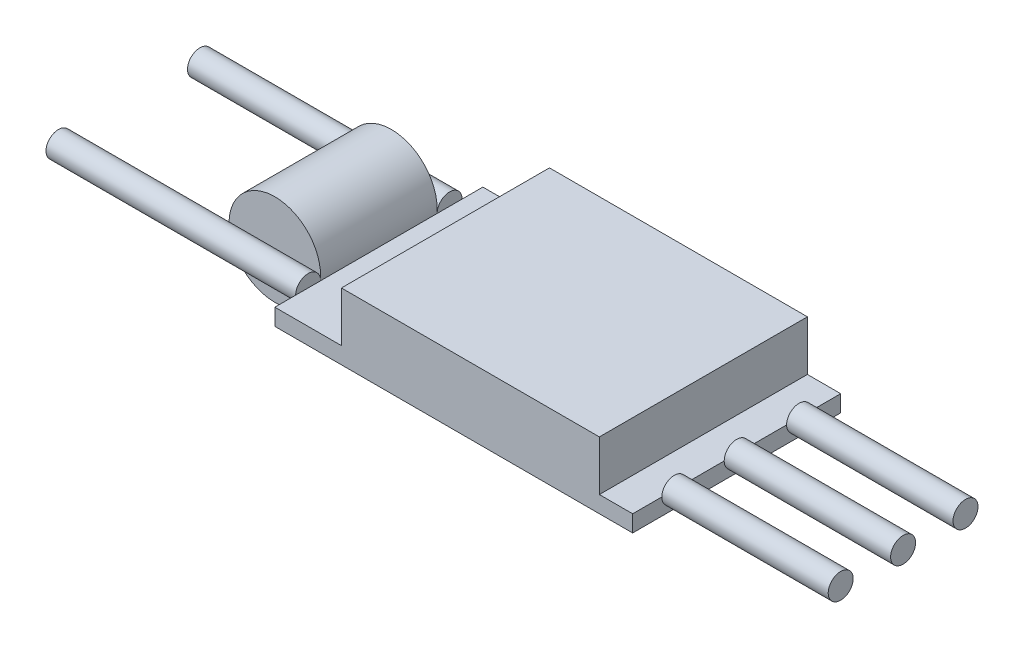
from build123d import *

# Parameters (mm, degrees)
SKETCH1_W           = 43
SKETCH1_H           = 25
BOSS_EXTRUDE1_DEPTH = 2
SKETCH2_R           = 5.5
BOSS_EXTRUDE2_DEPTH = 7
SKETCH3_W           = 31
SKETCH3_H           = 25
BOSS_EXTRUDE3_DEPTH = 6
SKETCH4_R           = 1.5
BOSS_EXTRUDE4_DEPTH = 30
SKETCH5_R           = 1.5
BOSS_EXTRUDE5_DEPTH = 20


with BuildPart() as part:
    # Sketch1 → Boss-Extrude1 (new body)
    with BuildSketch(Plane(origin=(0, 0, 0), x_dir=(1, 0, 0), z_dir=(0, 1, 0))):
        Rectangle(SKETCH1_W, SKETCH1_H)
    extrude(amount=BOSS_EXTRUDE1_DEPTH)

    # Sketch3 → Boss-Extrude3 (add)
    with BuildSketch(Plane(origin=(0, 2, 0), x_dir=(1, 0, 0), z_dir=(0, 1, 0))):
        with Locations((2, 0)):
            Rectangle(SKETCH3_W, SKETCH3_H)
    extrude(amount=BOSS_EXTRUDE3_DEPTH)

    # Sketch4 → Boss-Extrude4 (add)
    with BuildSketch(Plane.ZY.offset(21.5)):
        with Locations((-8.5, 2)):
            Circle(SKETCH4_R)
        with Locations((8.5, 2)):
            Circle(SKETCH4_R)
    extrude(amount=BOSS_EXTRUDE4_DEPTH)

    # Sketch5 → Boss-Extrude5 (add)
    with BuildSketch(Plane(origin=(21.5, 0, 0), x_dir=(0, 0, -1), z_dir=(1, 0, 0))):
        with Locations((-7.5, 2)):
            Circle(SKETCH5_R)
        with Locations((0, 2)):
            Circle(SKETCH5_R)
        with Locations((7.5, 2)):
            Circle(SKETCH5_R)
    extrude(amount=BOSS_EXTRUDE5_DEPTH)


with BuildPart() as body_2:
    # Sketch2 → Boss-Extrude2 (new body, symmetric)
    with BuildSketch(Plane.XY):
        with Locations((-27, 2.5)):
            Circle(SKETCH2_R)
    extrude(amount=BOSS_EXTRUDE2_DEPTH, both=True)


solid = Compound([part.part, body_2.part])
